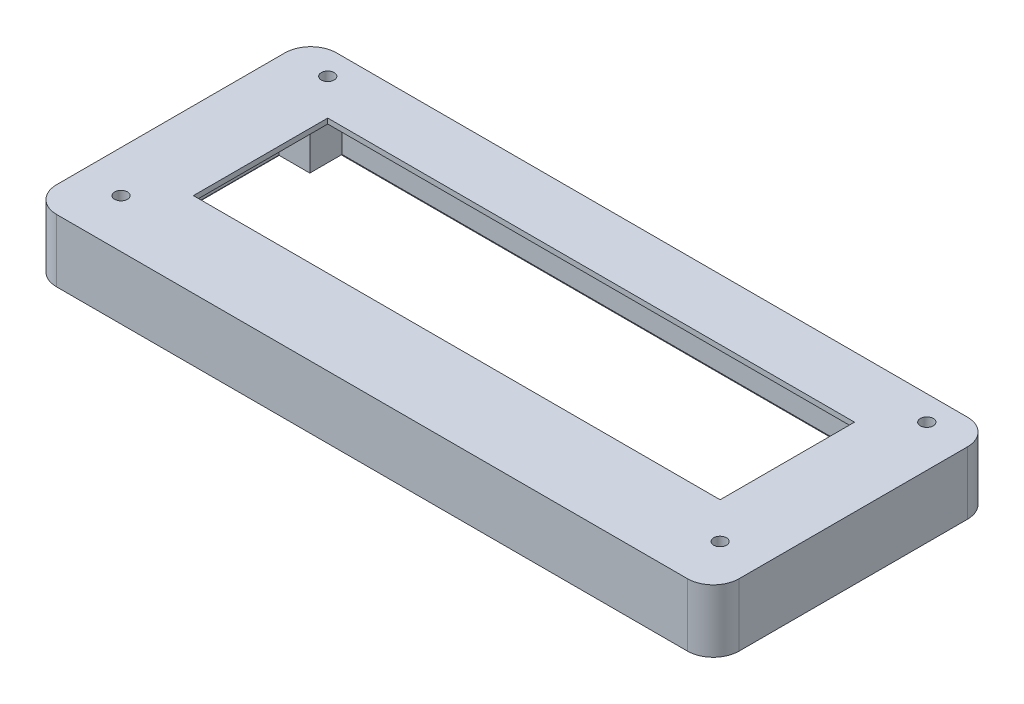
from build123d import *

# Parameters (mm, degrees)
SKETCH1_W                       = 132.15
SKETCH1_H                       = 54.2
SKETCH1_W_2                     = 102
SKETCH1_H_2                     = 26.02
BOSS_EXTRUDE6_DEPTH             = 12.15
CUT_EXTRUDE9_REACH              = 13.15
SKETCH3_W                       = 105
SKETCH3_H                       = 29.02
SKETCH4_W                       = 123.15
SKETCH4_H                       = 45.2
CUT_EXTRUDE10_DEPTH             = 2.15
TAP_DRILL_FOR_M3X0_5_TAP1_D     = 2.5
TAP_DRILL_FOR_M3X0_5_TAP1_DEPTH = 4
TAP_DRILL_FOR_M3X0_5_TAP1_TIP   = 0.751075774
CUT_EXTRUDE11_DEPTH             = 9
FILLET1_R                       = 5
TAP_DRILL_FOR_M3X0_5_TAP2_D     = 2.5
TAP_DRILL_FOR_M3X0_5_TAP2_DEPTH = 5
TAP_DRILL_FOR_M3X0_5_TAP2_TIP   = 0.751075774


with BuildPart() as part:
    # Sketch1 → Boss-Extrude6 (new body)
    with BuildSketch(Plane(origin=(0, 80.115132846, 0), x_dir=(1, 0, 0), z_dir=(0, 1, 0))):
        with Locations((49.760246528, -98.484153608)):
            Rectangle(SKETCH1_W, SKETCH1_H)
        with Locations((49.760246528, -96.174153608)):
            Rectangle(SKETCH1_W_2, SKETCH1_H_2, mode=Mode.SUBTRACT)
    extrude(amount=-BOSS_EXTRUDE6_DEPTH)

    # Sketch3 → Cut-Extrude9 (cut, up to next)
    with BuildSketch(Plane(origin=(0, 79.115132846, 0), x_dir=(1, 0, 0), z_dir=(0, 1, 0)), mode=Mode.PRIVATE) as cut_extrude9_sk1:
        with Locations((49.760246528, -96.174153608)):
            Rectangle(SKETCH3_W, SKETCH3_H)
    cut_extrude9_tool1 = extrude(cut_extrude9_sk1.sketch, amount=-CUT_EXTRUDE9_REACH, mode=Mode.PRIVATE) & part.part
    add(cut_extrude9_tool1.solids().sort_by_distance((49.760247, 79.115133, 96.174154))[0], mode=Mode.SUBTRACT)

    # Sketch4 → Cut-Extrude10 (cut)
    with BuildSketch(Plane.XZ.offset(-67.965132846)):
        with Locations((49.760246528, 98.484153608)):
            Rectangle(SKETCH4_W, SKETCH4_H)
    extrude(amount=-CUT_EXTRUDE10_DEPTH, mode=Mode.SUBTRACT)

    # Tap Drill for M3x0.5 Tap1
    with Locations(Plane(origin=(0, 70.115132846, 0), x_dir=(-1, 0, 0), z_dir=(0, -1, 0))):
        with Locations((-107.335246528, -79.884153608), (-107.335246528, -117.084153608), (7.814753472, -117.084153608), (7.814753472, -79.884153608)):
            Hole(TAP_DRILL_FOR_M3X0_5_TAP1_D / 2, depth=TAP_DRILL_FOR_M3X0_5_TAP1_DEPTH)
            with Locations((0, 0, -(TAP_DRILL_FOR_M3X0_5_TAP1_DEPTH + TAP_DRILL_FOR_M3X0_5_TAP1_TIP / 2))):  # 118° drill point
                Cone(0, TAP_DRILL_FOR_M3X0_5_TAP1_D / 2, TAP_DRILL_FOR_M3X0_5_TAP1_TIP, mode=Mode.SUBTRACT)

    # Sketch8 → Cut-Extrude11 (cut)
    with BuildSketch(Plane.XZ.offset(-70.115132846)):
        Polygon((103.260246528, 77.884153608), (103.260246528, 114.884153608), (-3.739753472, 114.884153608), (-3.739753472, 109.134153608), (-9.739753472, 109.134153608), (-9.739753472, 84.134153608), (-3.739753472, 84.134153608), (-3.739753472, 77.884153608), align=None)
    extrude(amount=-CUT_EXTRUDE11_DEPTH, mode=Mode.SUBTRACT)

    # Fillet1
    fillet1_edges = [part.edges().sort_by_distance(p)[0] for p in [
        (-16.314753472, 74.040132846, 71.384153608),
        (115.835246528, 74.040132846, 71.384153608),
        (115.835246528, 74.040132846, 125.584153608),
        (-16.314753472, 74.040132846, 125.584153608),
    ]]
    fillet(fillet1_edges, radius=FILLET1_R)

    # Tap Drill for M3x0.5 Tap2
    with Locations(Plane(origin=(0, 80.115132846, 0), x_dir=(1, 0, 0), z_dir=(0, 1, 0))):
        with Locations((-8.239753472, -76.164153608), (-8.239753472, -116.184153608), (107.760246528, -116.184153608), (107.760246528, -76.164153608)):
            Hole(TAP_DRILL_FOR_M3X0_5_TAP2_D / 2, depth=TAP_DRILL_FOR_M3X0_5_TAP2_DEPTH)
            with Locations((0, 0, -(TAP_DRILL_FOR_M3X0_5_TAP2_DEPTH + TAP_DRILL_FOR_M3X0_5_TAP2_TIP / 2))):  # 118° drill point
                Cone(0, TAP_DRILL_FOR_M3X0_5_TAP2_D / 2, TAP_DRILL_FOR_M3X0_5_TAP2_TIP, mode=Mode.SUBTRACT)


solid = part.part
